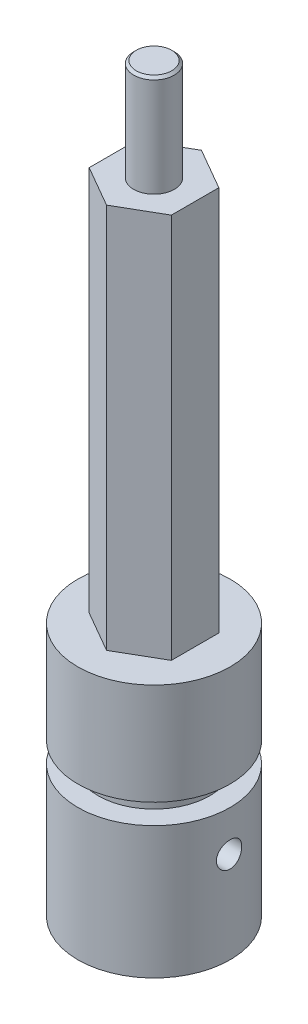
from build123d import *
from build123d.topology import SkipClean

# Parameters (mm, degrees)
SKETCH_1_R          = 7.5
EXTRUDE_1_DEPTH     = 25
EXTRUDE_2_DEPTH     = 38
CUT_EXTRUDE_1_DEPTH = 15
SKETCH_6_R          = 3
CUT_EXTRUDE_2_DEPTH = 3
M3X0_5_1_D          = 2.5
M3X0_5_1_DEPTH      = 5
SKETCH_21_R         = 3
CUT_EXTRUDE_3_DEPTH = 15
SKETCH_3_R          = 2
EXTRUDE_3_DEPTH     = 10
CHAMFER_1_SIZE      = 0.25
SKETCH_22_W         = 3.619891
SKETCH_22_H         = 2


with BuildPart() as part:
    # Sketch 1 → Extrude 1 (new body)
    with BuildSketch(Plane(origin=(0, 0, 0), x_dir=(1, 0, 0), z_dir=(0, 1, 0))):
        with Locations(Location((0, 0, 0), (0, 0, 270))):  # turned: the seam where the file's is
            Circle(SKETCH_1_R)
    extrude(amount=EXTRUDE_1_DEPTH)

    # Sketch 2 → Extrude 2 (add)
    with BuildSketch(Plane(origin=(0, 25, 0), x_dir=(1, 0, 0), z_dir=(0, 1, 0))):
        Polygon((0, -4.676537), (4.05, -2.338269), (4.05, 2.338269), (0, 4.676537), (-4.05, 2.338269), (-4.05, -2.338269), align=None)
    extrude(amount=EXTRUDE_2_DEPTH)

    # Sketch 5 → Cut-Extrude 1 (cut)
    with BuildSketch(Plane.XZ):
        with BuildLine():
            Line((2.5, 1.658312), (2.5, -1.658312))
            ThreePointArc((2.5, -1.658312), (-3, 0), (2.5, 1.658312))
        make_face()
    extrude(amount=-CUT_EXTRUDE_1_DEPTH, mode=Mode.SUBTRACT)

    # Sketch 6 → Cut-Extrude 2 (cut)
    with SkipClean():  # keep this step's faces unmerged: merging them makes the solid invalid here
        with BuildSketch(Plane.XZ):
            with Locations(Location((0, 0, 0), (0, 0, 270))):  # turned: the seam where the file's is
                Circle(SKETCH_6_R)
        extrude(amount=-CUT_EXTRUDE_2_DEPTH, mode=Mode.SUBTRACT)

    # M3x0.5 _1
    with Locations(Plane.ZY.offset(-2.5)):
        with Locations((0, 9)):
            Hole(M3X0_5_1_D / 2, depth=M3X0_5_1_DEPTH)

    # Sketch 21 → Cut-Extrude 3 (cut)
    with SkipClean():  # keep this step's faces unmerged: merging them makes the solid invalid here
        with BuildSketch(Plane.XZ):
            with Locations(Location((0, 0, 0), (0, 0, 270))):  # turned: the seam where the file's is
                Circle(SKETCH_21_R)
        extrude(amount=-CUT_EXTRUDE_3_DEPTH, mode=Mode.SUBTRACT)

    # Sketch 3 → Extrude 3 (add)
    with SkipClean():  # keep this step's faces unmerged: merging them makes the solid invalid here
        with BuildSketch(Plane(origin=(0, 63, 0), x_dir=(1, 0, 0), z_dir=(0, 1, 0))):
            with Locations(Location((0, 0, 0), (0, 0, 270))):  # turned: the seam where the file's is
                Circle(SKETCH_3_R)
        extrude(amount=EXTRUDE_3_DEPTH)

    # Chamfer 1
    chamfer_1_edges = [part.edges().sort_by_distance(p)[0] for p in [
        (0, 73, -2),
    ]]
    chamfer(chamfer_1_edges, length=CHAMFER_1_SIZE)

    # Sketch 22 → Cut-Revolve 1 (revolve, cut)
    with SkipClean():  # keep this step's faces unmerged: merging them makes the solid invalid here
        with BuildSketch(Plane.XY, mode=Mode.PRIVATE) as cut_revolve_1_sk:
            with Locations((7.309945, 14)):
                Rectangle(SKETCH_22_W, SKETCH_22_H)
        revolve(cut_revolve_1_sk.sketch.rotate(Axis((0, 25, 0), (0, -1, 0)), 90), axis=Axis((0, 25, 0), (0, -1, 0)), mode=Mode.SUBTRACT)  # turned: the seam where the file's is


solid = part.part
